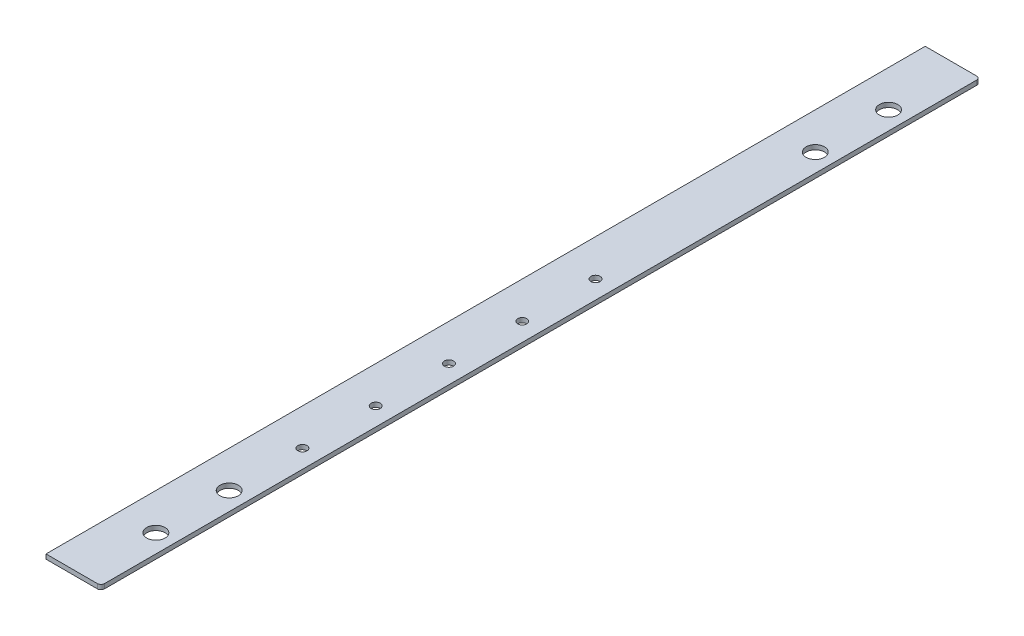
from build123d import *

# Parameters (mm, degrees)
SKETCH1_W           = 38.1
SKETCH1_H           = 609.6
BOSS_EXTRUDE1_DEPTH = 3.175
FILLET1_R           = 2.54
SKETCH4_R           = 3.175
SKETCH4_R_2         = 6.35
CUT_EXTRUDE1_DEPTH  = 4.175


with BuildPart() as part:
    # Sketch1 → Boss-Extrude1 (new body)
    with BuildSketch(Plane(origin=(0, 0, 0), x_dir=(1, 0, 0), z_dir=(0, 1, 0))):
        with Locations((19.05, 304.8)):
            Rectangle(SKETCH1_W, SKETCH1_H)
    extrude(amount=BOSS_EXTRUDE1_DEPTH)

    # Fillet1
    fillet1_edges = [part.edges().sort_by_distance(p)[0] for p in [
        (38.1, 1.5875, -609.6),
        (38.1, 1.5875, 0),
    ]]
    fillet(fillet1_edges, radius=FILLET1_R)

    # Sketch4 → Cut-Extrude1 (cut, through all)
    with BuildSketch(Plane(origin=(0, 3.175, 0), x_dir=(-1, 0, 0), z_dir=(0, 1, 0))):
        with Locations((-25.4, -152.4)):
            Circle(SKETCH4_R)
        with Locations((-25.4, -203.2)):
            Circle(SKETCH4_R)
        with Locations((-25.4, -254)):
            Circle(SKETCH4_R)
        with Locations((-25.4, -304.8)):
            Circle(SKETCH4_R)
        with Locations((-25.4, -355.6)):
            Circle(SKETCH4_R)
        with Locations((-25.4, -50.8)):
            Circle(SKETCH4_R_2)
        with Locations((-25.4, -101.6)):
            Circle(SKETCH4_R_2)
        with Locations((-25.4, -558.8)):
            Circle(SKETCH4_R_2)
        with Locations((-25.4, -508)):
            Circle(SKETCH4_R_2)
    extrude(amount=-CUT_EXTRUDE1_DEPTH, mode=Mode.SUBTRACT)


solid = part.part
